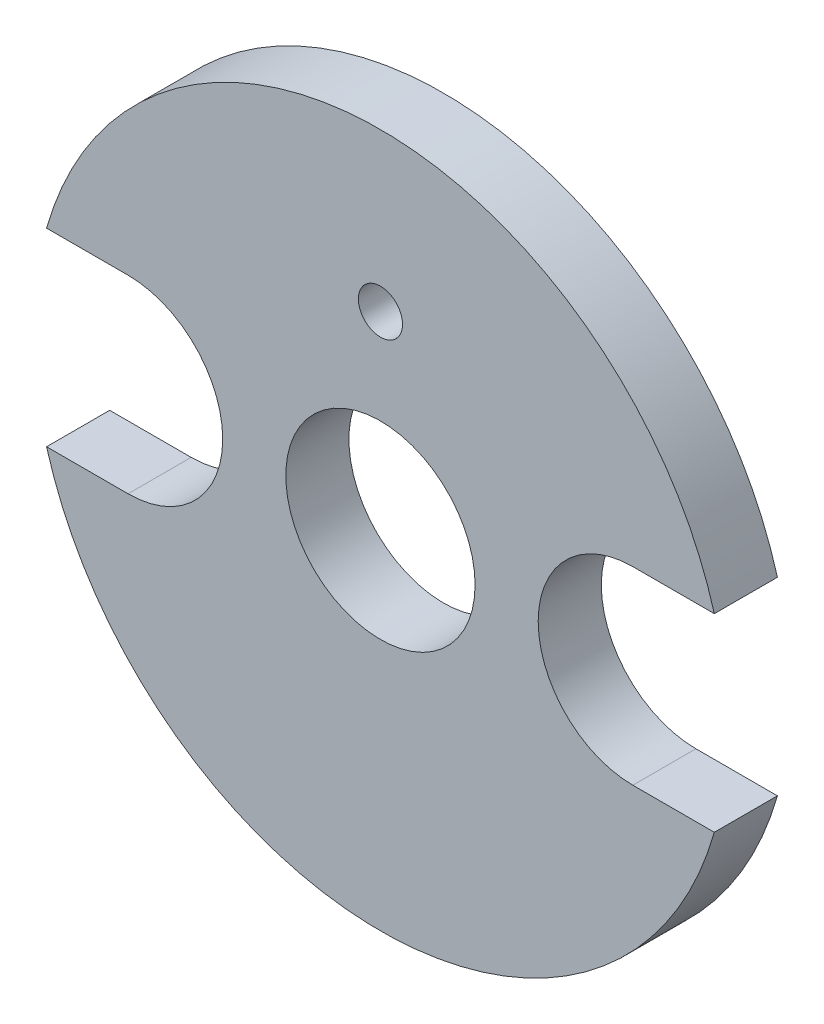
from build123d import *

# Parameters (mm, degrees)
MODEL_R             = 0.7
MODEL_R_2           = 3
BOSS_EXTRUDE1_DEPTH = 2


with BuildPart() as part:
    # Model → Boss-Extrude1 (new body)
    with BuildSketch(Plane.XY):
        with BuildLine():
            Line((-8, 3), (-10.583005244, 3))
            ThreePointArc((-10.583005244, 3), (0, 11), (10.583005244, 3))
            Line((10.583005244, 3), (8, 3))
            ThreePointArc((8, 3), (5, 0), (8, -3))
            Line((8, -3), (10.583005244, -3))
            ThreePointArc((10.583005244, -3), (0, -11), (-10.583005244, -3))
            Line((-10.583005244, -3), (-8, -3))
            ThreePointArc((-8, -3), (-5, 0), (-8, 3))
        make_face()
        with Locations((0, 6)):
            Circle(MODEL_R, mode=Mode.SUBTRACT)
        Circle(MODEL_R_2, mode=Mode.SUBTRACT)
    extrude(amount=BOSS_EXTRUDE1_DEPTH)


solid = part.part
